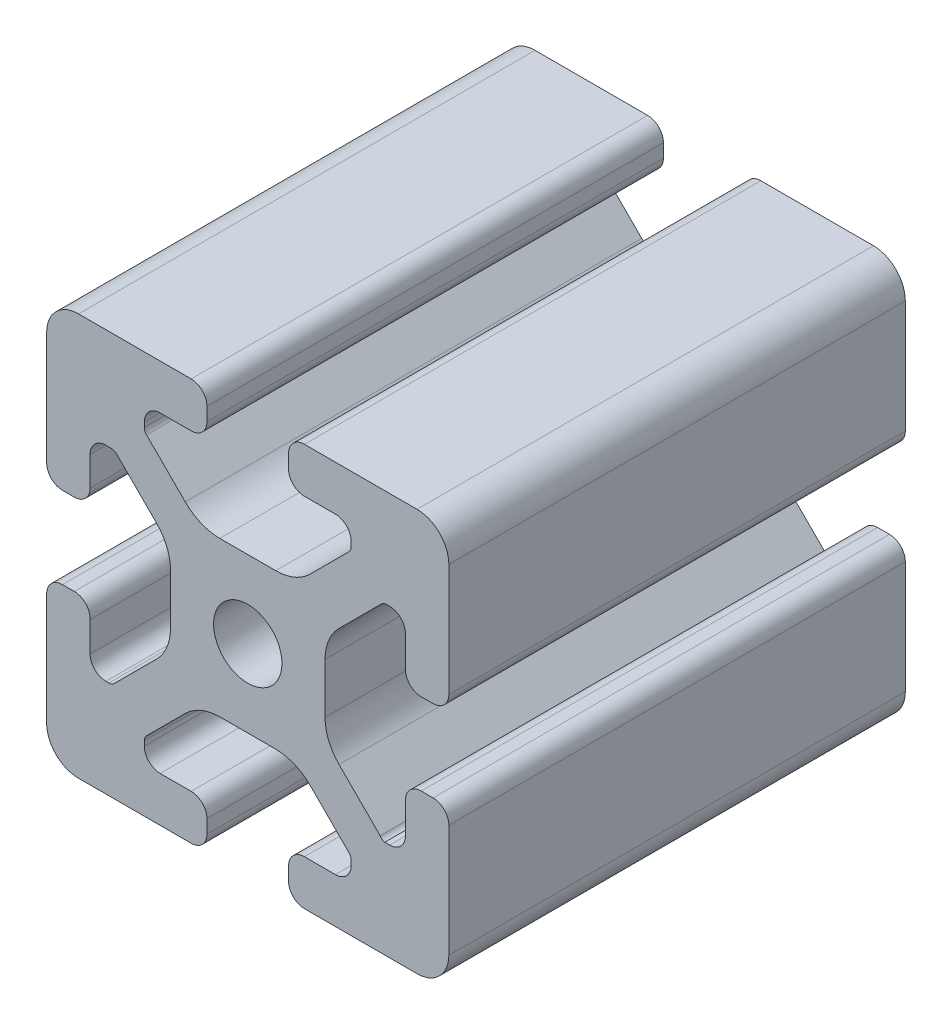
from build123d import *

# Parameters (mm, degrees)
SKETCH1_R      = 3.4
EXTRUDE1_DEPTH = 45.4


with BuildPart() as part:
    # Sketch1 → Extrude1 (new body)
    with BuildSketch(Plane.XY):
        with BuildLine():
            Line((-8.715, -15.524615034), (-5.63, -15.524615034))
            ThreePointArc((-5.63, -15.524615034), (-4.519842354, -15.984457388), (-4.06, -17.094615034))
            Line((-4.06, -17.094615034), (-4.06, -18.43))
            ThreePointArc((-4.06, -18.43), (-4.519842354, -19.540157646), (-5.63, -20))
            Line((-5.63, -20), (-16.674615034, -20))
            ThreePointArc((-16.674615034, -20), (-18.951578385, -19.194274381), (-20, -17.018368134))
            Line((-20, -17.018368134), (-20, -5.757918808))
            ThreePointArc((-20, -5.757918808), (-19.564709668, -4.603883664), (-18.43, -4.120449326))
            Line((-18.43, -4.120449326), (-17.25, -4.120449326))
            ThreePointArc((-17.25, -4.120449326), (-16.115287682, -4.60388249), (-15.67999625, -5.757919334))
            Line((-15.67999625, -5.757919334), (-15.67999625, -8.715399492))
            ThreePointArc((-15.67999625, -8.715399492), (-15.220153896, -9.825557139), (-14.10999625, -10.285399492))
            Line((-14.10999625, -10.285399492), (-13.816898819, -10.285399492))
            ThreePointArc((-13.816898819, -10.285399492), (-13.526061711, -10.227547119), (-13.279501941, -10.062800646))
            Line((-13.279501941, -10.062800646), (-9.076242789, -5.859541495))
            ThreePointArc((-9.076242789, -5.859541495), (-8.046572221, -4.318530588), (-7.685, -2.500784284))
            Line((-7.685, -2.500784284), (-7.685, 2.500784284))
            ThreePointArc((-7.685, 2.500784284), (-8.046572221, 4.318530588), (-9.076242789, 5.859541495))
            Line((-9.076242789, 5.859541495), (-13.040489136, 9.823787841))
            ThreePointArc((-13.040489136, 9.823787841), (-13.354224618, 10.012729352), (-13.71989919, 10.033001362))
            Line((-13.71989919, 10.033001362), (-14.05520779, 10.044710596))
            ThreePointArc((-14.05520779, 10.044710596), (-15.200613642, 9.605030484), (-15.68, 8.475666998))
            Line((-15.68, 8.475666998), (-15.68, 5.572979049))
            ThreePointArc((-15.68, 5.572979049), (-16.139842354, 4.462821403), (-17.25, 4.002979049))
            Line((-17.25, 4.002979049), (-18.43, 4.002979049))
            ThreePointArc((-18.43, 4.002979049), (-19.540157646, 4.462821403), (-20, 5.572979049))
            Line((-20, 5.572979049), (-20, 13.004526564))
            Line((-20, 13.004526564), (-20, 16.83))
            ThreePointArc((-20, 16.83), (-19.071528496, 19.071528496), (-16.83, 20))
            Line((-16.83, 20), (-5.63, 20))
            ThreePointArc((-5.63, 20), (-4.519842354, 19.540157646), (-4.06, 18.43))
            Line((-4.06, 18.43), (-4.06, 17.094615034))
            ThreePointArc((-4.06, 17.094615034), (-4.519842354, 15.984457388), (-5.63, 15.524615034))
            Line((-5.63, 15.524615034), (-8.715, 15.524615034))
            ThreePointArc((-8.715, 15.524615034), (-9.825157646, 15.06477268), (-10.285, 13.954615034))
            Line((-10.285, 13.954615034), (-10.285, 13.492503602))
            ThreePointArc((-10.285, 13.492503602), (-10.227148445, 13.201664194), (-10.062401154, 12.955102448))
            Line((-10.062401154, 12.955102448), (-6.217092793, 9.109794088))
            ThreePointArc((-6.217092793, 9.109794088), (-4.63891877, 8.055291919), (-2.777335583, 7.685))
            Line((-2.777335583, 7.685), (2.777335583, 7.685))
            ThreePointArc((2.777335583, 7.685), (4.63891877, 8.055291919), (6.217092793, 9.109794088))
            Line((6.217092793, 9.109794088), (10.062401154, 12.955102448))
            ThreePointArc((10.062401154, 12.955102448), (10.227148445, 13.201664194), (10.285, 13.492503602))
            Line((10.285, 13.492503602), (10.285, 13.954615034))
            ThreePointArc((10.285, 13.954615034), (9.825157646, 15.06477268), (8.715, 15.524615034))
            Line((8.715, 15.524615034), (5.63, 15.524615034))
            ThreePointArc((5.63, 15.524615034), (4.519842354, 15.984457388), (4.06, 17.094615034))
            Line((4.06, 17.094615034), (4.06, 18.43))
            ThreePointArc((4.06, 18.43), (4.519842354, 19.540157646), (5.63, 20))
            Line((5.63, 20), (12.979635074, 20))
            Line((12.979635074, 20), (16.83, 20))
            ThreePointArc((16.83, 20), (19.071528496, 19.071528496), (20, 16.83))
            Line((20, 16.83), (20, 13.001098436))
            Line((20, 13.001098436), (20, 5.63))
            ThreePointArc((20, 5.63), (19.540157461, 4.519842693), (18.43, 4.060000526))
            Line((18.43, 4.060000526), (17.24999625, 4.060000526))
            ThreePointArc((17.24999625, 4.060000526), (16.139838603, 4.519842879), (15.67999625, 5.630000526))
            Line((15.67999625, 5.630000526), (15.67999625, 8.715399492))
            ThreePointArc((15.67999625, 8.715399492), (15.220153896, 9.825557139), (14.10999625, 10.285399492))
            Line((14.10999625, 10.285399492), (13.816903094, 10.285399492))
            ThreePointArc((13.816903094, 10.285399492), (13.526063686, 10.227547937), (13.279501941, 10.062800646))
            Line((13.279501941, 10.062800646), (9.076242789, 5.859541495))
            ThreePointArc((9.076242789, 5.859541495), (8.046572221, 4.318530588), (7.685, 2.500784284))
            Line((7.685, 2.500784284), (7.685, -2.500784284))
            ThreePointArc((7.685, -2.500784284), (8.046572221, -4.318530588), (9.076242789, -5.859541495))
            Line((9.076242789, -5.859541495), (13.163657296, -9.946956002))
            ThreePointArc((13.163657296, -9.946956002), (13.35903797, -10.160433474), (13.6200547, -10.285399492))
            Line((13.6200547, -10.285399492), (14.10999625, -10.285399492))
            ThreePointArc((14.10999625, -10.285399492), (15.220153896, -9.825557139), (15.67999625, -8.715399492))
            Line((15.67999625, -8.715399492), (15.67999625, -5.630000526))
            ThreePointArc((15.67999625, -5.630000526), (16.139838603, -4.519842879), (17.24999625, -4.060000526))
            Line((17.24999625, -4.060000526), (18.43, -4.060000526))
            ThreePointArc((18.43, -4.060000526), (19.540157461, -4.519842693), (20, -5.63))
            Line((20, -5.63), (20, -16.83))
            ThreePointArc((20, -16.83), (19.071528496, -19.071528496), (16.83, -20))
            Line((16.83, -20), (13, -20))
            Line((13, -20), (5.63, -20))
            ThreePointArc((5.63, -20), (4.519842354, -19.540157646), (4.06, -18.43))
            Line((4.06, -18.43), (4.06, -17.094615034))
            ThreePointArc((4.06, -17.094615034), (4.519842354, -15.984457388), (5.63, -15.524615034))
            Line((5.63, -15.524615034), (8.715, -15.524615034))
            ThreePointArc((8.715, -15.524615034), (9.825157646, -15.06477268), (10.285, -13.954615034))
            Line((10.285, -13.954615034), (10.285, -13.492503602))
            ThreePointArc((10.285, -13.492503602), (10.227148445, -13.201664194), (10.062401154, -12.955102448))
            Line((10.062401154, -12.955102448), (6.217092793, -9.109794088))
            ThreePointArc((6.217092793, -9.109794088), (4.63891877, -8.055291919), (2.777335583, -7.685))
            Line((2.777335583, -7.685), (-2.777335583, -7.685))
            ThreePointArc((-2.777335583, -7.685), (-4.63891877, -8.055291919), (-6.217092793, -9.109794088))
            Line((-6.217092793, -9.109794088), (-10.062401154, -12.955102448))
            ThreePointArc((-10.062401154, -12.955102448), (-10.227148445, -13.201664194), (-10.285, -13.492503602))
            Line((-10.285, -13.492503602), (-10.285, -13.954615034))
            ThreePointArc((-10.285, -13.954615034), (-9.825157646, -15.06477268), (-8.715, -15.524615034))
        make_face()
        Circle(SKETCH1_R, mode=Mode.SUBTRACT)
    extrude(amount=-EXTRUDE1_DEPTH)


solid = part.part
